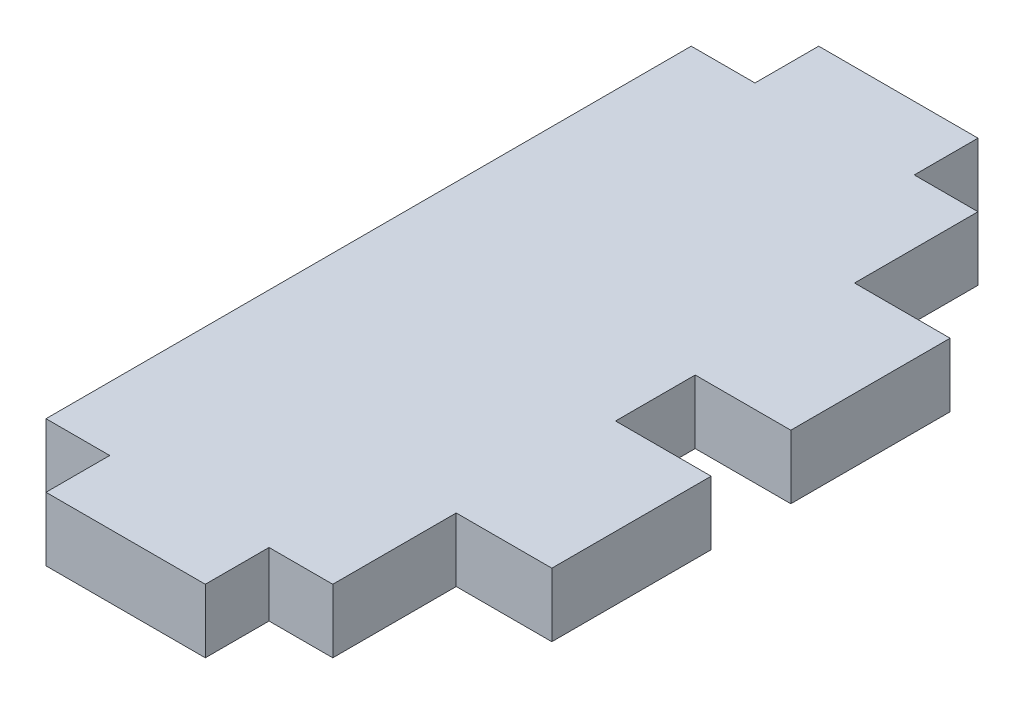
from build123d import *

# Parameters (mm, degrees)
SKETCH1_W           = 18
SKETCH1_H           = 40.5
BOSS_EXTRUDE1_DEPTH = 4
SKETCH2_W           = 10
SKETCH2_H           = 4
BOSS_EXTRUDE2_DEPTH = 4
SKETCH3_W           = 10
SKETCH3_H           = 4
BOSS_EXTRUDE3_DEPTH = 6


with BuildPart() as part:
    # Sketch1 → Boss-Extrude1 (new body)
    with BuildSketch(Plane(origin=(0, 0, 0), x_dir=(1, 0, 0), z_dir=(0, 1, 0))):
        with Locations((9, -20.25)):
            Rectangle(SKETCH1_W, SKETCH1_H)
    extrude(amount=BOSS_EXTRUDE1_DEPTH)

    # Sketch2 → Boss-Extrude2 (add, through all)
    with BuildSketch(Plane(origin=(0, 0, 0), x_dir=(-1, 0, 0), z_dir=(0, -1, 0))):
        with Locations((-9, 2)):
            Rectangle(SKETCH2_W, SKETCH2_H)
        with Locations((-9, -42.5)):
            Rectangle(SKETCH2_W, SKETCH2_H)
    extrude(amount=-BOSS_EXTRUDE2_DEPTH)

    # Sketch3 → Boss-Extrude3 (add)
    with BuildSketch(Plane(origin=(18, 0, 0), x_dir=(0, 0, -1), z_dir=(1, 0, 0))):
        with Locations((-12.75, 2)):
            Rectangle(SKETCH3_W, SKETCH3_H)
        with Locations((-27.75, 2)):
            Rectangle(SKETCH3_W, SKETCH3_H)
    extrude(amount=BOSS_EXTRUDE3_DEPTH)


solid = part.part
